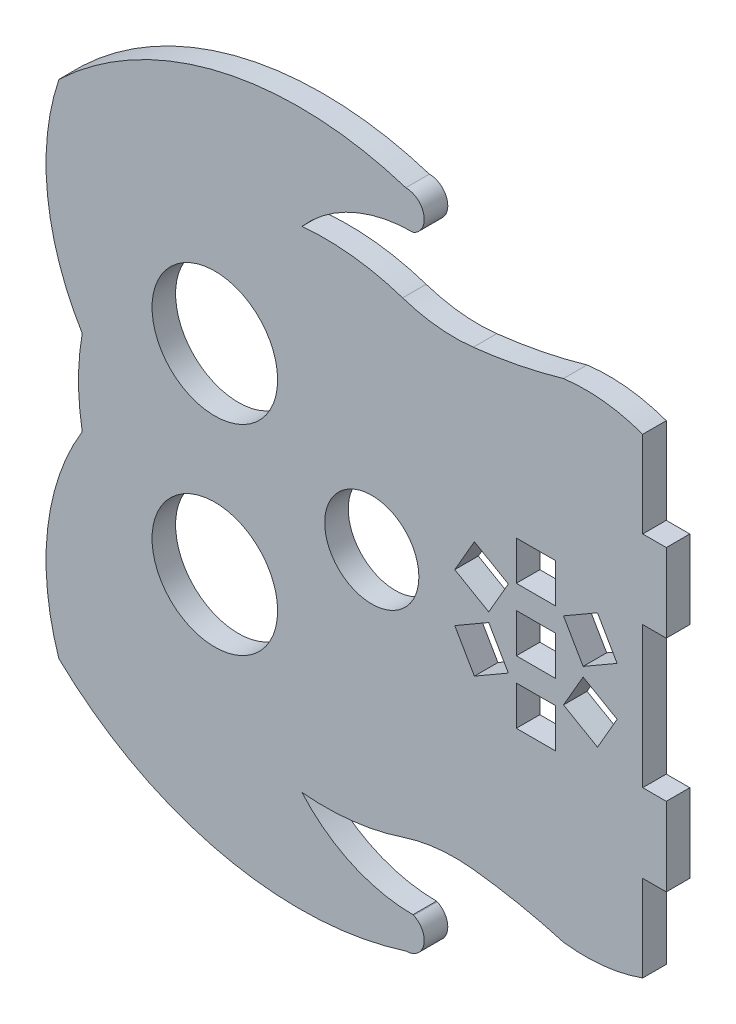
from build123d import *

# Parameters (mm, degrees)
SKETCH2_R           = 8
SKETCH2_R_2         = 6
SKETCH2_W           = 5
SKETCH2_H           = 5
BOSS_EXTRUDE1_DEPTH = 3


with BuildPart() as part:
    # Sketch2 → Boss-Extrude1 (new body)
    with BuildSketch(Plane.XY):
        with BuildLine():
            Line((81.032103119, 50.181312), (81.032103119, 60.181312))
            Line((81.032103119, 60.181312), (78.032103119, 60.181312))
            Line((78.032103119, 60.181312), (78.032103119, 71.181312))
            ThreePointArc((78.032103119, 71.181312), (73.050090858, 72.33654353), (67.936161846, 72.284235691))
            ThreePointArc((67.936161846, 72.284235691), (62.235942644, 70.892785416), (56.438402104, 69.988818319))
            ThreePointArc((56.438402104, 69.988818319), (51.886102873, 69.971964975), (47.437133801, 70.93653043))
            ThreePointArc((47.437133801, 70.93653043), (41.102316828, 72.343050119), (34.613643935, 72.416041905))
            ThreePointArc((34.613643935, 72.416041905), (40.990344282, 77.154811793), (48.755286163, 78.83526559))
            ThreePointArc((48.755286163, 78.83526559), (48.80614848, 78.851120911), (48.85704212, 78.866875402))
            ThreePointArc((48.85704212, 78.866875402), (50.134187725, 81.487874692), (47.847872498, 83.297156554))
            ThreePointArc((47.847872498, 83.297156554), (24.351235249, 84.294658733), (3.641458375, 73.150507154))
            ThreePointArc((3.641458375, 73.150507154), (2.19654611, 59.548103084), (6.61028157, 46.600821237))
            ThreePointArc((6.61028157, 46.600821237), (6.138572184, 41.181312), (6.61028157, 35.761802763))
            ThreePointArc((6.61028157, 35.761802763), (2.19654611, 22.814520916), (3.641458375, 9.212116846))
            ThreePointArc((3.641458375, 9.212116846), (24.351235249, -1.932034733), (47.847872498, -0.934532554))
            ThreePointArc((47.847872498, -0.934532554), (50.134187725, 0.874749308), (48.85704212, 3.495748598))
            ThreePointArc((48.85704212, 3.495748598), (48.80614848, 3.511503089), (48.755286163, 3.52735841))
            ThreePointArc((48.755286163, 3.52735841), (40.990344282, 5.207812207), (34.613643935, 9.946582095))
            ThreePointArc((34.613643935, 9.946582095), (41.102316828, 10.019573881), (47.437133801, 11.42609357))
            ThreePointArc((47.437133801, 11.42609357), (51.886102873, 12.390659025), (56.438402104, 12.373805681))
            ThreePointArc((56.438402104, 12.373805681), (62.235942644, 11.469838584), (67.936161846, 10.078388309))
            ThreePointArc((67.936161846, 10.078388309), (73.050090858, 10.02608047), (78.032103119, 11.181312))
            Line((78.032103119, 11.181312), (78.032103119, 22.181312))
            Line((78.032103119, 22.181312), (81.032103119, 22.181312))
            Line((81.032103119, 22.181312), (81.032103119, 32.181312))
            Line((81.032103119, 32.181312), (78.032103119, 32.181312))
            Line((78.032103119, 32.181312), (78.032103119, 50.181312))
            Line((78.032103119, 50.181312), (81.032103119, 50.181312))
        make_face()
        with Locations((23.507028058, 53.931312)):
            Circle(SKETCH2_R, mode=Mode.SUBTRACT)
        with Locations((43.507028058, 41.181312)):
            Circle(SKETCH2_R_2, mode=Mode.SUBTRACT)
        with Locations((23.507028058, 28.431312)):
            Circle(SKETCH2_R, mode=Mode.SUBTRACT)
        with Locations((64.423022125, 41.181312)):
            Rectangle(SKETCH2_W, SKETCH2_H, mode=Mode.SUBTRACT)
        with Locations((64.423022125, 33.181312)):
            Rectangle(SKETCH2_W, SKETCH2_H, mode=Mode.SUBTRACT)
        Polygon((72.266288865, 48.59637551), (67.936161846, 46.09637551), (70.436161846, 41.766248491), (74.766288865, 44.266248491), align=None, mode=Mode.SUBTRACT)
        Polygon((67.936161846, 36.266248491), (72.266288865, 33.766248491), (74.766288865, 38.09637551), (70.436161846, 40.596375509), align=None, mode=Mode.SUBTRACT)
        with Locations((64.423022125, 49.181312)):
            Rectangle(SKETCH2_W, SKETCH2_H, mode=Mode.SUBTRACT)
        Polygon((56.579755385, 33.766248491), (60.909882404, 36.266248491), (58.409882404, 40.59637551), (54.079755385, 38.09637551), align=None, mode=Mode.SUBTRACT)
        Polygon((60.909882404, 46.09637551), (56.579755385, 48.596375509), (54.079755385, 44.266248491), (58.409882404, 41.766248491), align=None, mode=Mode.SUBTRACT)
    extrude(amount=BOSS_EXTRUDE1_DEPTH)


solid = part.part
